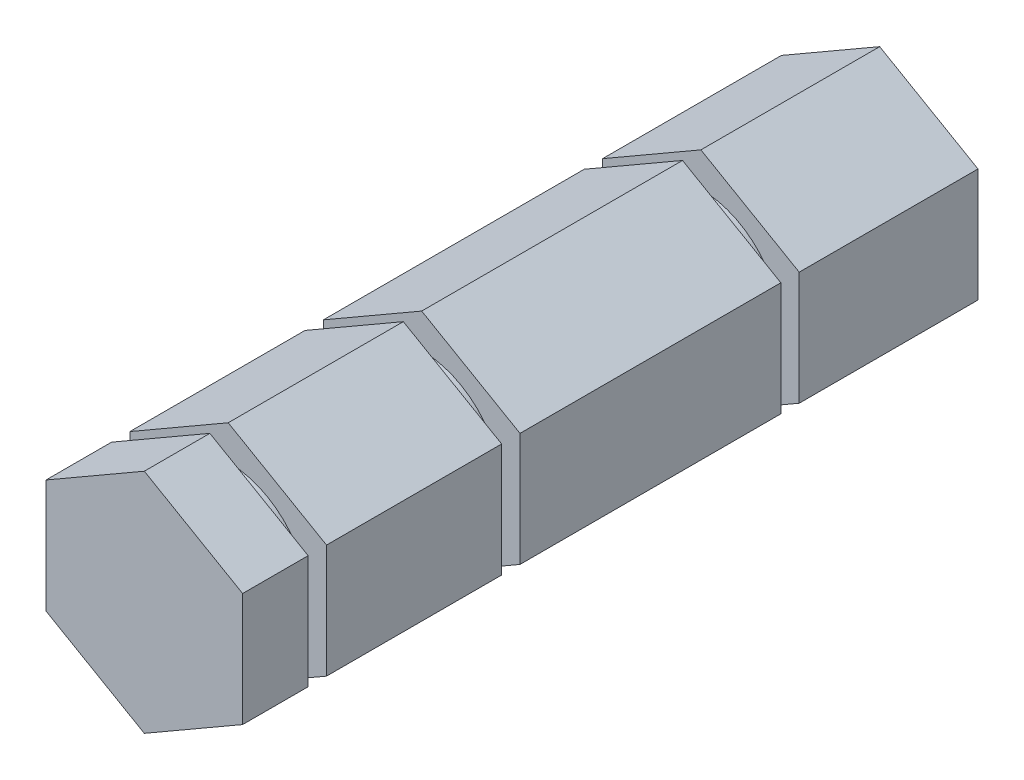
from build123d import *

# Parameters (mm, degrees)
BOSS_EXTRUDE1_DEPTH = 40.6146
SKETCH5_W           = 11.10345239
SKETCH5_H           = 12.145052052
SKETCH5_R           = 3.8481
CUT_EXTRUDE2_DEPTH  = 0.4445
SKETCH10_W          = 12.002544197
SKETCH10_H          = 11.794166694
SKETCH10_R          = 3.8481
CUT_EXTRUDE7_DEPTH  = 0.4445
SKETCH9_W           = 11.366817307
SKETCH9_H           = 11.947942936
SKETCH9_R           = 3.8481
CUT_EXTRUDE6_DEPTH  = 0.4445
SKETCH11_R          = 5.745102087
CUT_EXTRUDE8_DEPTH  = 4.9911


with BuildPart() as part:
    # Sketch1 → Boss-Extrude1 (new body)
    with BuildSketch(Plane.XY):
        Polygon((0, 5.499261314), (-4.7625, 2.749630657), (-4.7625, -2.749630657), (0, -5.499261314), (4.7625, -2.749630657), (4.7625, 2.749630657), align=None)
    extrude(amount=BOSS_EXTRUDE1_DEPTH)

    # Sketch5 → Cut-Extrude2 (cut, symmetric)
    with BuildSketch(Plane(origin=(0, 0, 22.6314), x_dir=(-1, 0, 0), z_dir=(0, 0, -1))):
        with Locations((-0.378227241, -0.09440181)):
            Rectangle(SKETCH5_W, SKETCH5_H)
        Circle(SKETCH5_R, mode=Mode.SUBTRACT)
    extrude(amount=CUT_EXTRUDE2_DEPTH, both=True, mode=Mode.SUBTRACT)

    # Sketch10 → Cut-Extrude7 (cut, symmetric)
    with BuildSketch(Plane(origin=(0, 0, 32.004), x_dir=(-1, 0, 0), z_dir=(0, 0, -1))):
        with Locations((-0.081621529, -0.253464989)):
            Rectangle(SKETCH10_W, SKETCH10_H)
        Circle(SKETCH10_R, mode=Mode.SUBTRACT)
    extrude(amount=CUT_EXTRUDE7_DEPTH, both=True, mode=Mode.SUBTRACT)

    # Sketch9 → Cut-Extrude6 (cut, symmetric)
    with BuildSketch(Plane.XY.offset(9.1059)):
        with Locations((0.130537015, 0.158516672)):
            Rectangle(SKETCH9_W, SKETCH9_H)
        Circle(SKETCH9_R, mode=Mode.SUBTRACT)
    extrude(amount=CUT_EXTRUDE6_DEPTH, both=True, mode=Mode.SUBTRACT)

    # Sketch11 → Cut-Extrude8 (cut)
    with BuildSketch(Plane.XY.offset(40.6146)):
        Circle(SKETCH11_R)
    extrude(amount=-CUT_EXTRUDE8_DEPTH, mode=Mode.SUBTRACT)


solid = part.part
